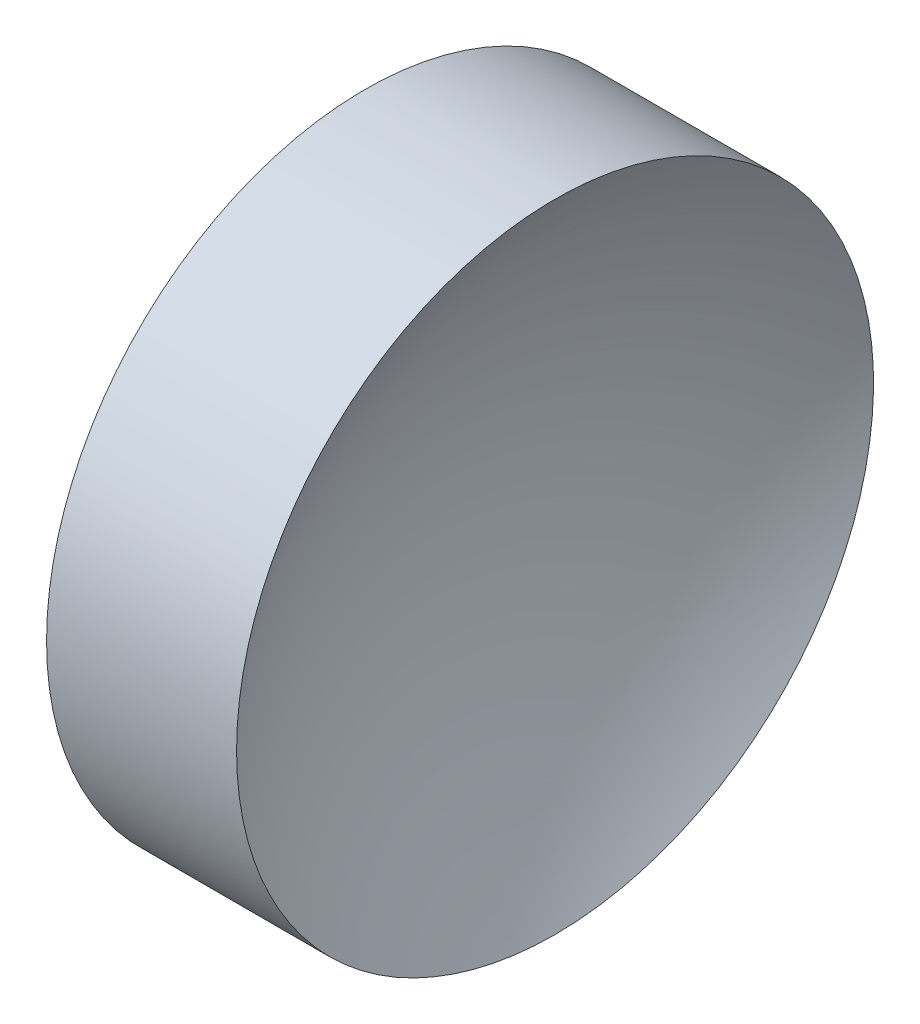
from build123d import *


with BuildPart() as part:
    # 草图1 → 旋转1 (revolve)
    with BuildSketch(Plane.XY, mode=Mode.PRIVATE) as revolve_1_sk:
        with BuildLine():
            Line((41.365827325, 26.062252183), (41.365827325, 31.062252183))
            Line((41.365827325, 31.062252183), (44.348896859, 31.062252183))
            ThreePointArc((44.348896859, 31.062252183), (43.244409568, 28.669908949), (42.865827325, 26.062252183))
            Line((42.865827325, 26.062252183), (41.365827325, 26.062252183))
        make_face()
    revolve(revolve_1_sk.sketch.rotate(Axis((39.736500013, 26.062252183, 0), (1, 0, 0)), 180), axis=Axis((39.736500013, 26.062252183, 0), (1, 0, 0)))  # turned: the seam where the file's is


solid = part.part
